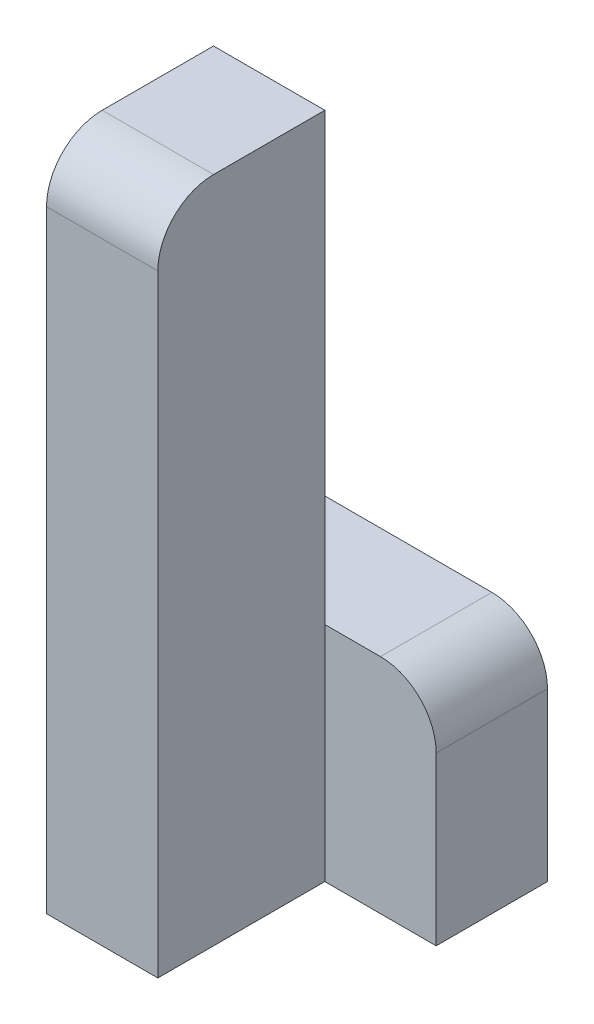
from build123d import *

# Parameters (mm, degrees)
SKETCH1_W           = 20
SKETCH1_H           = 120
BOSS_EXTRUDE1_DEPTH = 30
SKETCH2_W           = 40
SKETCH2_H           = 40
BOSS_EXTRUDE2_DEPTH = 20
FILLET1_R           = 10


with BuildPart() as part:
    # Sketch1 → Boss-Extrude1 (new body)
    with BuildSketch(Plane.XY):
        with Locations((-20, -60)):
            Rectangle(SKETCH1_W, SKETCH1_H)
    extrude(amount=BOSS_EXTRUDE1_DEPTH)

    # Sketch2 → Boss-Extrude2 (add)
    with BuildSketch(Plane.XY):
        with Locations((-10, -100)):
            Rectangle(SKETCH2_W, SKETCH2_H)
    extrude(amount=-BOSS_EXTRUDE2_DEPTH)

    # Fillet1
    fillet1_edges = [part.edges().sort_by_distance(p)[0] for p in [
        (10, -80, -10),
        (-20, 0, 30),
    ]]
    fillet(fillet1_edges, radius=FILLET1_R)


solid = part.part
